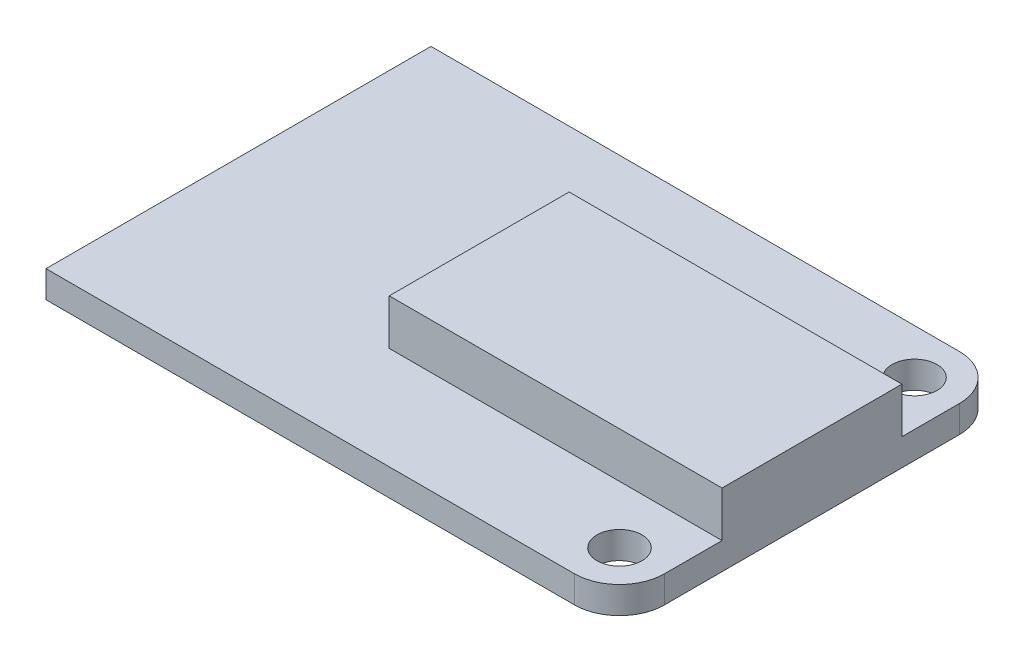
from build123d import *

# Parameters (mm, degrees)
SKETCH1_R           = 1.25
BOSS_EXTRUDE1_DEPTH = 1.5
SKETCH3_W           = 18.5
SKETCH3_H           = 10
BOSS_EXTRUDE2_DEPTH = 2.53


with BuildPart() as part:
    # Sketch1 → Boss-Extrude1 (new body)
    with BuildSketch(Plane(origin=(0, 0, 0), x_dir=(1, 0, 0), z_dir=(0, 1, 0))):
        with BuildLine():
            Line((31.88, 2.5), (31.88, 18.9))
            ThreePointArc((31.88, 18.9), (31.147766953, 20.667766953), (29.38, 21.4))
            Line((29.38, 21.4), (0, 21.4))
            Line((0, 21.4), (0, 0))
            Line((0, 0), (29.38, 0))
            ThreePointArc((29.38, 0), (31.147766953, 0.732233047), (31.88, 2.5))
        make_face()
        with Locations((29.38, 2.5)):
            Circle(SKETCH1_R, mode=Mode.SUBTRACT)
        with Locations((29.38, 18.9)):
            Circle(SKETCH1_R, mode=Mode.SUBTRACT)
    extrude(amount=BOSS_EXTRUDE1_DEPTH)

    # Sketch3 → Boss-Extrude2 (add)
    with BuildSketch(Plane(origin=(0, 1.5, 0), x_dir=(1, 0, 0), z_dir=(0, 1, 0))):
        with Locations((22.63, 10.7)):
            Rectangle(SKETCH3_W, SKETCH3_H)
    extrude(amount=BOSS_EXTRUDE2_DEPTH)


solid = part.part
